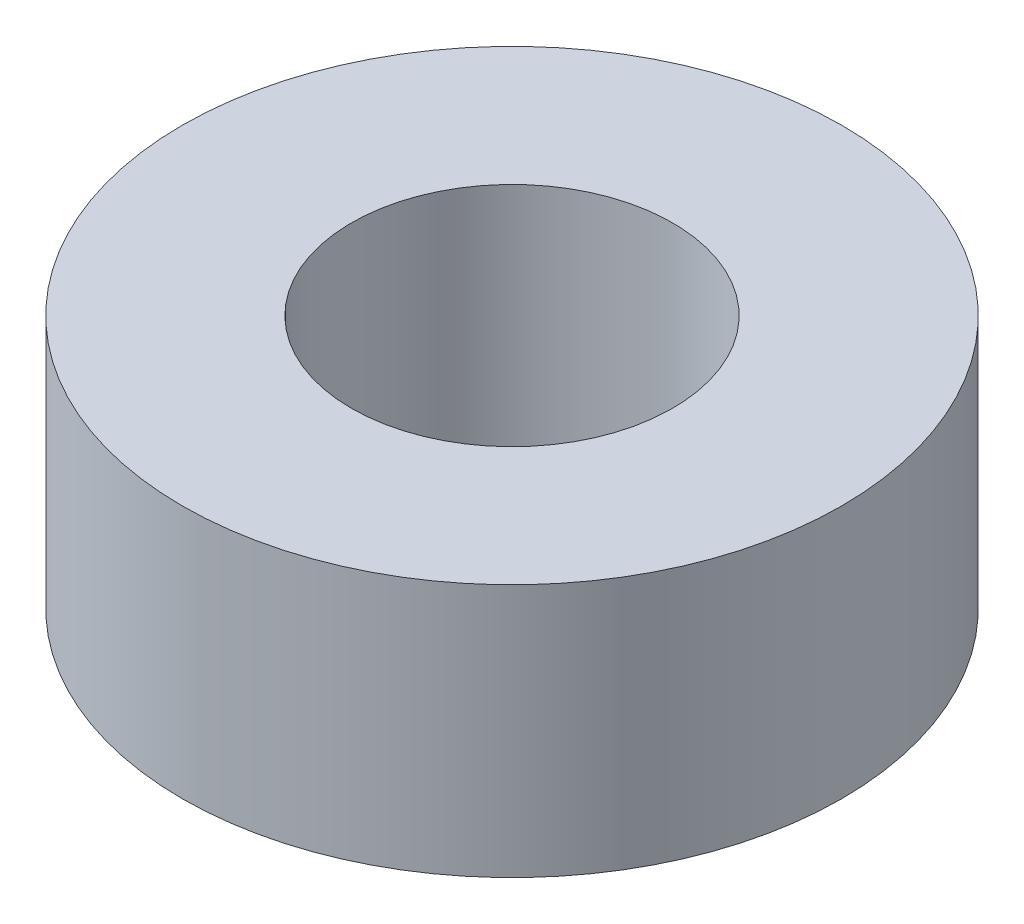
from build123d import *

# Parameters (mm, degrees)
SKETCH_1_R      = 3.9
SKETCH_1_R_2    = 1.9
EXTRUDE_1_DEPTH = 3


with BuildPart() as part:
    # 草图1 → 拉伸-薄壁1 (new body)
    with BuildSketch(Plane(origin=(0, 0, 0), x_dir=(1, 0, 0), z_dir=(0, 1, 0))):
        Circle(SKETCH_1_R)
        Circle(SKETCH_1_R_2, mode=Mode.SUBTRACT)
    extrude(amount=EXTRUDE_1_DEPTH)


solid = part.part
